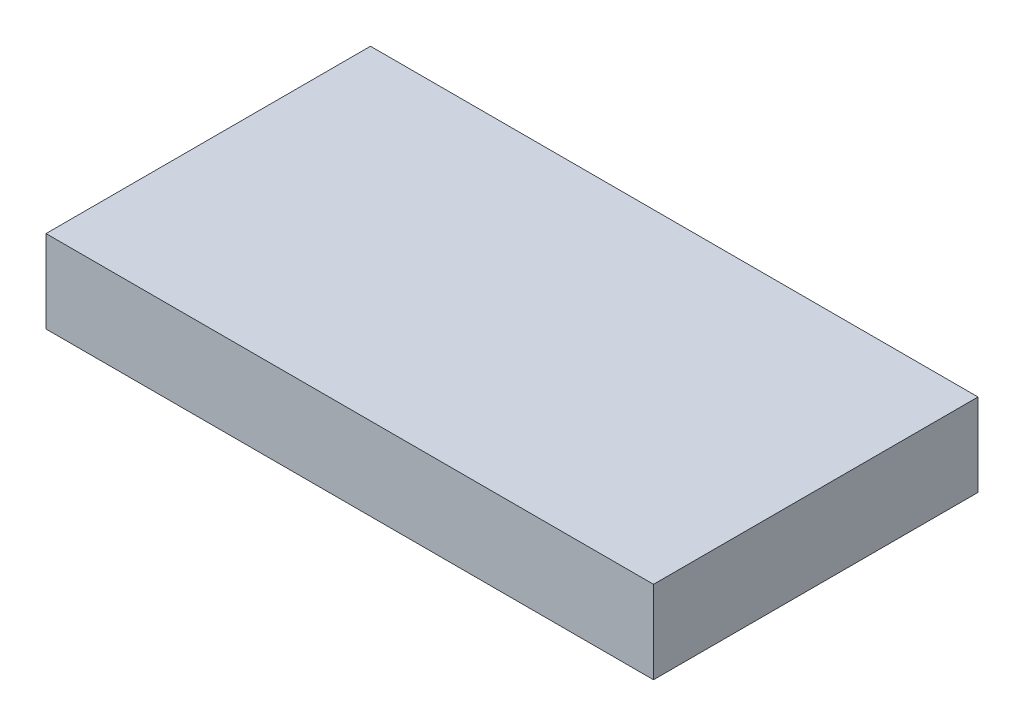
from build123d import *

# Parameters (mm, degrees)
SKETCH1_W           = 28.14
SKETCH1_H           = 15.03
BOSS_EXTRUDE1_DEPTH = 3.83


with BuildPart() as part:
    # Sketch1 → Boss-Extrude1 (new body)
    with BuildSketch(Plane(origin=(0, 0, 0), x_dir=(1, 0, 0), z_dir=(0, 1, 0))):
        with Locations((14.07, -7.515)):
            Rectangle(SKETCH1_W, SKETCH1_H)
    extrude(amount=BOSS_EXTRUDE1_DEPTH)


solid = part.part
